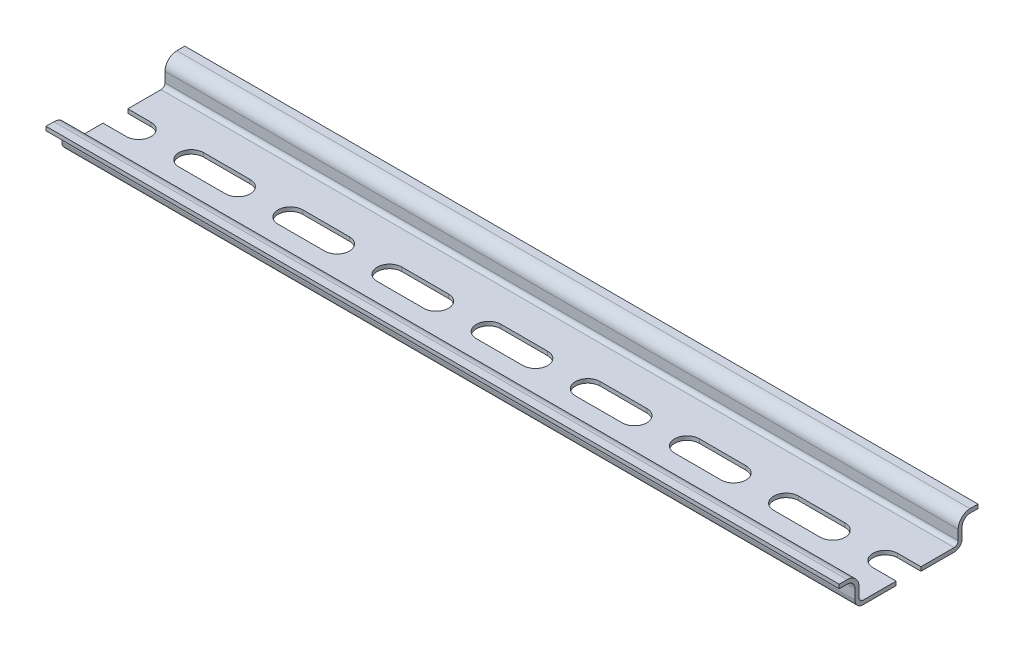
from build123d import *

# Parameters (mm, degrees)
EXTRUDE_THIN1_DEPTH = 200
CUT_EXTRUDE1_DEPTH  = 1
LPATTERN1_COUNT     = 9
LPATTERN1_PITCH     = 25


with BuildPart() as part:
    # Sketch1 → Extrude-Thin1 (new body)
    with BuildSketch(Plane(origin=(0, 0, 0), x_dir=(0, 0, -1), z_dir=(1, 0, 0))):
        with BuildLine():
            Line((-17.5, 6.5), (-15.5, 6.5))
            ThreePointArc((-15.5, 6.5), (-14.085786438, 5.914213562), (-13.5, 4.5))
            Line((-13.5, 4.5), (-13.5, 2))
            ThreePointArc((-13.5, 2), (-12.914213562, 0.585786438), (-11.5, 0))
            Line((-11.5, 0), (11.5, 0))
            ThreePointArc((11.5, 0), (12.914213562, 0.585786438), (13.5, 2))
            Line((13.5, 2), (13.5, 4.5))
            ThreePointArc((13.5, 4.5), (14.085786438, 5.914213562), (15.5, 6.5))
            Line((15.5, 6.5), (17.5, 6.5))
            Line((17.5, 6.5), (17.5, 7.5))
            Line((17.5, 7.5), (15.5, 7.5))
            ThreePointArc((15.5, 7.5), (13.378679656, 6.621320344), (12.5, 4.5))
            Line((12.5, 4.5), (12.5, 2))
            ThreePointArc((12.5, 2), (12.207106781, 1.292893219), (11.5, 1))
            Line((11.5, 1), (-11.5, 1))
            ThreePointArc((-11.5, 1), (-12.207106781, 1.292893219), (-12.5, 2))
            Line((-12.5, 2), (-12.5, 4.5))
            ThreePointArc((-12.5, 4.5), (-13.378679656, 6.621320344), (-15.5, 7.5))
            Line((-15.5, 7.5), (-17.5, 7.5))
            Line((-17.5, 7.5), (-17.5, 6.5))
        make_face()
    extrude(amount=EXTRUDE_THIN1_DEPTH)

    # Sketch2 → Cut-Extrude1 (cut)
    with BuildSketch(Plane.XZ):
        with BuildLine():
            Line((-5.875, 3.125), (5.875, 3.125))
            ThreePointArc((5.875, 3.125), (9, 0), (5.875, -3.125))
            Line((5.875, -3.125), (-5.875, -3.125))
            ThreePointArc((-5.875, -3.125), (-9, 0), (-5.875, 3.125))
        make_face()
    cut_extrude1 = extrude(amount=-CUT_EXTRUDE1_DEPTH, mode=Mode.SUBTRACT)

    # LPattern1: Cut-Extrude1 ×9
    with Locations(*[(i * LPATTERN1_PITCH, 0, 0) for i in range(1, LPATTERN1_COUNT)]):
        add(cut_extrude1, mode=Mode.SUBTRACT)


solid = part.part
